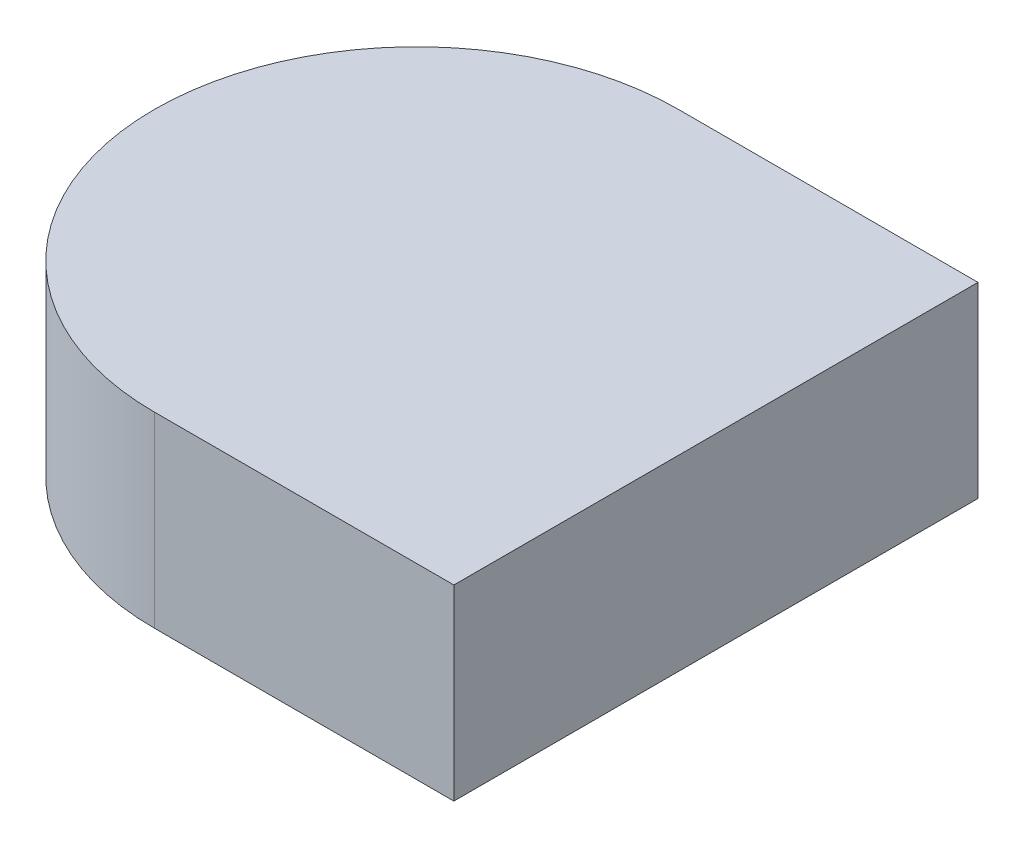
from build123d import *

# Parameters (mm, degrees)
SKETCH1_W               = 10.16
SKETCH1_H               = 3.175
BOSS_EXTRUDE1_DEPTH     = 4.445
SKETCH3_OUTSIDE_W       = 14.934
SKETCH3_OUTSIDE_H       = 13.664
SKETCH3_OUTSIDE_W_2     = 10.16
SKETCH3_OUTSIDE_H_2     = 8.89
SKETCH3_OUTSIDE_W_3     = 5.08
SKETCH3_OUTSIDE_H_3     = 5.08
CUT_EXTRUDE1_DEPTH      = 1.905
CUT_EXTRUDE2_DEPTH      = 1
CUT_EXTRUDE2_DEPTH_BACK = 4.175
SKETCH6_R               = 1.5875
CUT_EXTRUDE3_DEPTH      = 0.2032


with BuildPart() as part:
    # Sketch1 → Boss-Extrude1 (new body, symmetric)
    with BuildSketch(Plane.XY):
        with Locations((0, -1.5875)):
            Rectangle(SKETCH1_W, SKETCH1_H)
    extrude(amount=BOSS_EXTRUDE1_DEPTH, both=True)

    # Sketch3 outside → Cut-Extrude1 (cut)
    with BuildSketch(Plane.XZ.offset(3.175)):
        Rectangle(SKETCH3_OUTSIDE_W, SKETCH3_OUTSIDE_H)
        Rectangle(SKETCH3_OUTSIDE_W_2, SKETCH3_OUTSIDE_H_2, mode=Mode.SUBTRACT)
        Rectangle(SKETCH3_OUTSIDE_W_3, SKETCH3_OUTSIDE_H_3)
    extrude(amount=-CUT_EXTRUDE1_DEPTH, mode=Mode.SUBTRACT)

    # Sketch5 → Cut-Extrude2 (cut, two sides)
    with BuildSketch(Plane(origin=(0, 0, 0), x_dir=(1, 0, 0), z_dir=(0, 1, 0))) as cut_extrude2_sk:
        with BuildLine():
            Line((0, 4.445), (-5.08, 4.445))
            Line((-5.08, 4.445), (-5.08, -4.445))
            Line((-5.08, -4.445), (0, -4.445))
            ThreePointArc((0, -4.445), (-4.445, 0), (0, 4.445))
        make_face()
    extrude(amount=CUT_EXTRUDE2_DEPTH, mode=Mode.SUBTRACT)
    extrude(cut_extrude2_sk.sketch, amount=-CUT_EXTRUDE2_DEPTH_BACK, mode=Mode.SUBTRACT)

    # Sketch6 → Cut-Extrude3 (cut)
    with BuildSketch(Plane.XZ.offset(1.27)):
        Circle(SKETCH6_R)
    extrude(amount=-CUT_EXTRUDE3_DEPTH, mode=Mode.SUBTRACT)


solid = part.part
